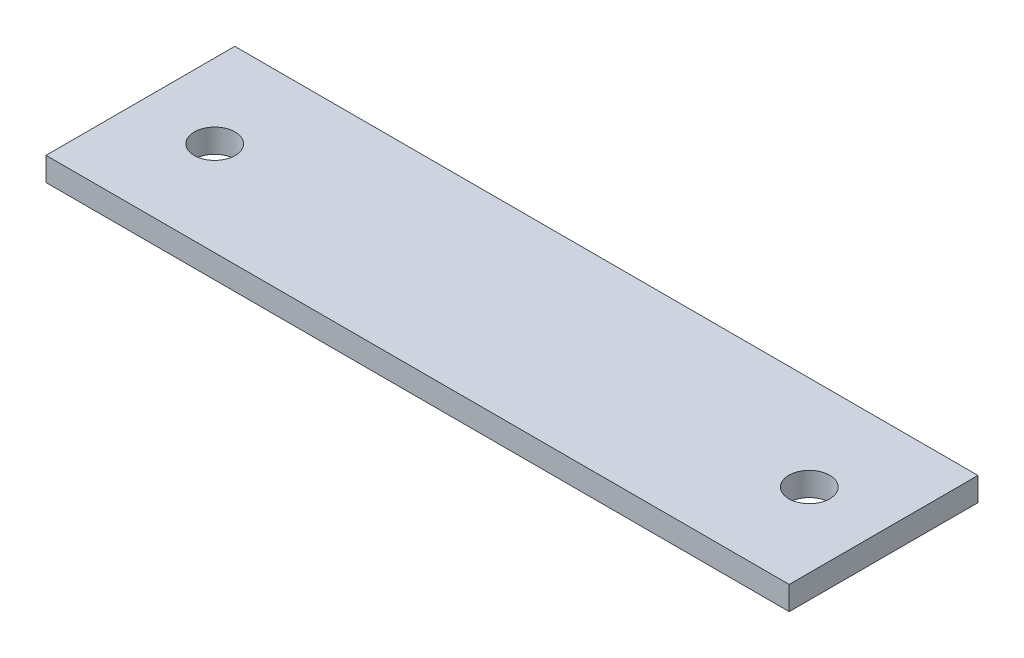
from build123d import *

# Parameters (mm, degrees)
SKETCH1_W                = 100
SKETCH1_H                = 25.4
BOSS_EXTRUDE1_DEPTH      = 3.175
M5_CLEARANCE_HOLE1_D     = 5.5
M5_CLEARANCE_HOLE1_DEPTH = 12.446
M5_CLEARANCE_HOLE1_TIP   = 1.652366702


with BuildPart() as part:
    # Sketch1 → Boss-Extrude1 (new body)
    with BuildSketch(Plane(origin=(0, 0, 0), x_dir=(1, 0, 0), z_dir=(0, 1, 0))):
        with Locations((50, 12.7)):
            Rectangle(SKETCH1_W, SKETCH1_H)
    extrude(amount=BOSS_EXTRUDE1_DEPTH)

    # M5 Clearance Hole1
    with Locations(Plane(origin=(10, 3.175, -12.7), x_dir=(0, 0, 1), z_dir=(0, 1, 0))):
        with Locations((0, 0), (0, 80)):
            Hole(M5_CLEARANCE_HOLE1_D / 2, depth=M5_CLEARANCE_HOLE1_DEPTH)
            with Locations((0, 0, -(M5_CLEARANCE_HOLE1_DEPTH + M5_CLEARANCE_HOLE1_TIP / 2))):  # 118° drill point
                Cone(0, M5_CLEARANCE_HOLE1_D / 2, M5_CLEARANCE_HOLE1_TIP, mode=Mode.SUBTRACT)


solid = part.part
